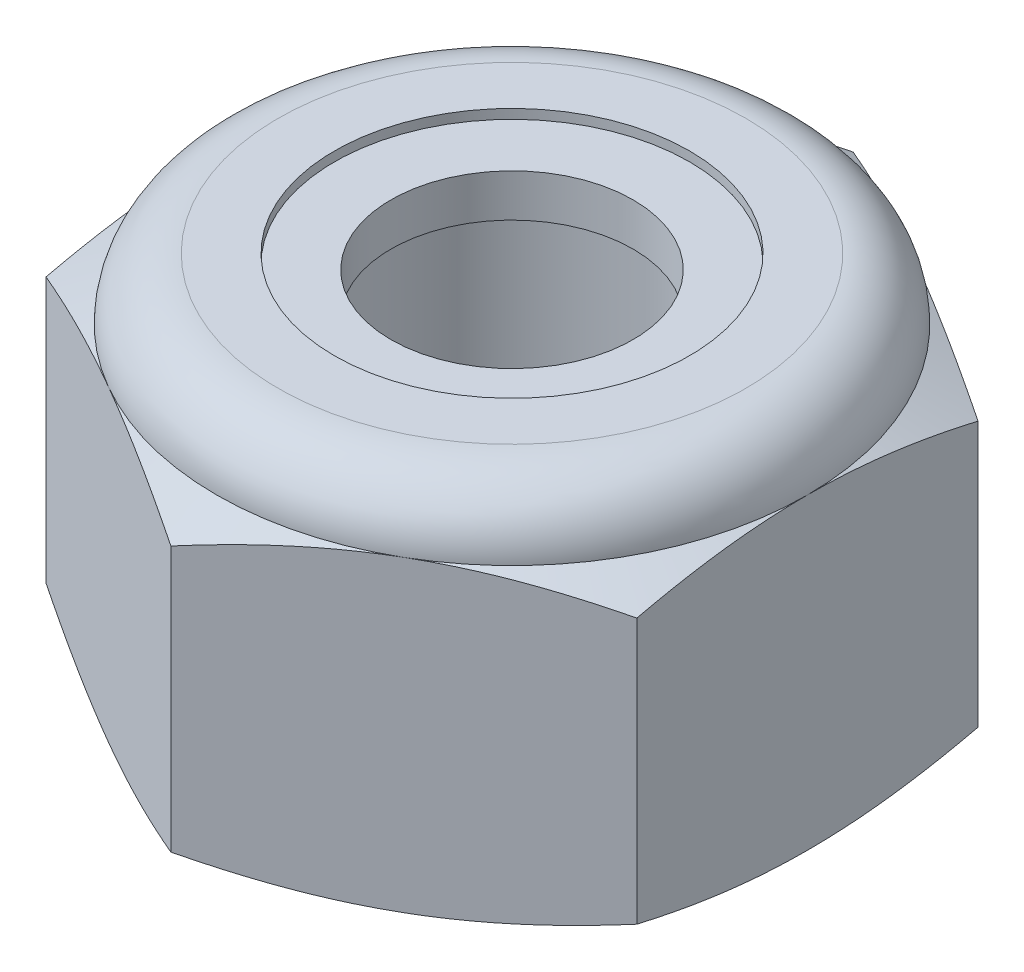
from build123d import *

# Parameters (mm, degrees)
EXTRUDE1_DEPTH = 5.953125
SKETCH2_W      = 2.413
SKETCH2_H      = 5.953125


with BuildPart() as part:
    # Sketch1 → Extrude1 (new body)
    with BuildSketch(Plane(origin=(0, 0, 0), x_dir=(1, 0, 0), z_dir=(0, 1, 0))):
        Polygon((0, 5.499261314), (-4.7625, 2.749630657), (-4.7625, -2.749630657), (0, -5.499261314), (4.7625, -2.749630657), (4.7625, 2.749630657), align=None)
    extrude(amount=EXTRUDE1_DEPTH)

    # Sketch4 → Cut-Revolve2 (revolve, cut)
    with BuildSketch(Plane(origin=(0, 0, 0), x_dir=(0, 0, -1), z_dir=(1, 0, 0))):
        Polygon((0, 5.953125), (2.413, 5.953125), (1.952639712, 5.738455472), (1.952639712, 0.214669528), (2.413, 0), (0, 0), align=None)
    revolve(axis=Axis((0, 5.953125, 0), (0, 1, 0)), mode=Mode.SUBTRACT)


with BuildPart() as body_2:
    # Sketch2 → Revolve1 (revolve)
    with BuildSketch(Plane(origin=(0, 0, 0), x_dir=(0, 0, -1), z_dir=(1, 0, 0))):
        with Locations((1.2065, 2.9765625)):
            Rectangle(SKETCH2_W, SKETCH2_H)
    revolve(axis=Axis((0, -2.413, 0), (0, 1, 0)))


with BuildPart() as part_1:
    add(part.part)

    # Combine1: cut body 2
    add(body_2.part, mode=Mode.SUBTRACT)

    # Sketch5 → Cut-Revolve3 (revolve, cut)
    with BuildSketch(Plane(origin=(0, 0, 0), x_dir=(0, 0, -1), z_dir=(1, 0, 0))):
        with BuildLine():
            Line((0, 0), (4.7625, 0))
            Line((4.7625, 0), (5.499261314, 0.343557443))
            Line((5.499261314, 0.343557443), (5.499261314, 4.617380057))
            Line((5.499261314, 4.617380057), (4.7625, 4.9609375))
            ThreePointArc((4.7625, 4.9609375), (4.471895009, 5.662520009), (3.7703125, 5.953125))
            Line((3.7703125, 5.953125), (3.7703125, 7.223125))
            Line((3.7703125, 7.223125), (6.769261314, 7.223125))
            Line((6.769261314, 7.223125), (6.769261314, -1.27))
            Line((6.769261314, -1.27), (0, -1.27))
            Line((0, -1.27), (0, 0))
        make_face()
    revolve(axis=Axis((0, 0, 0), (0, 1, 0)), mode=Mode.SUBTRACT)

    # Sketch6 → Cut-Revolve4 (revolve, cut)
    with BuildSketch(Plane(origin=(0, 0, 0), x_dir=(0, 0, -1), z_dir=(1, 0, 0))):
        with BuildLine():
            Line((0, 4.9609375), (4.6101, 4.9609375))
            ThreePointArc((4.6101, 4.9609375), (4.364131936, 5.554756936), (3.7703125, 5.800725))
            Line((3.7703125, 5.800725), (2.861476106, 5.800725))
            Line((2.861476106, 5.800725), (2.861476106, 7.223125))
            Line((2.861476106, 7.223125), (0, 7.223125))
            Line((0, 7.223125), (0, 4.9609375))
        make_face()
    revolve(axis=Axis((0, 7.223125, 0), (0, 1, 0)), mode=Mode.SUBTRACT)


with BuildPart() as body_2_2:
    # Sketch7 → Revolve2 (revolve)
    with BuildSketch(Plane(origin=(0, 0, 0), x_dir=(0, 0, -1), z_dir=(1, 0, 0))):
        with BuildLine():
            Line((1.952639712, 5.0371375), (4.530088408, 5.0371375))
            ThreePointArc((4.530088408, 5.0371375), (4.282601726, 5.527175629), (3.7703125, 5.724525))
            Line((3.7703125, 5.724525), (1.952639712, 5.724525))
            Line((1.952639712, 5.724525), (1.952639712, 5.0371375))
        make_face()
    revolve(axis=Axis((0, 5.0371375, 0), (0, 1, 0)))


solid = Compound([part_1.part, body_2_2.part])
